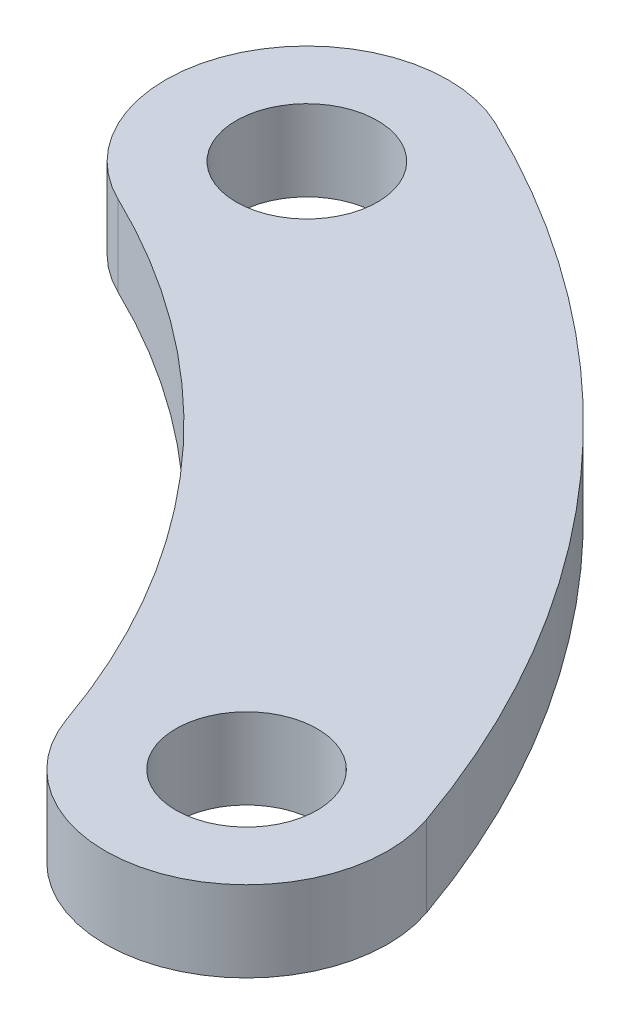
from build123d import *

# Parameters (mm, degrees)
SKETCH1_R           = 1.75
BOSS_EXTRUDE1_DEPTH = 2


with BuildPart() as part:
    # Sketch1 → Boss-Extrude1 (new body)
    with BuildSketch(Plane(origin=(0, 2, 0), x_dir=(1, 0, 0), z_dir=(0, 1, 0))):
        with BuildLine():
            ThreePointArc((26.108282991, 9.103848595), (20.637016257, 18.402066732), (12.023950872, 24.898737025))
            ThreePointArc((12.023950872, 24.898737025), (7.350192911, 23.269017259), (8.979912677, 18.595259297))
            ThreePointArc((8.979912677, 18.595259297), (15.412455179, 13.743315661), (19.498591095, 6.799076799))
            ThreePointArc((19.498591095, 6.799076799), (23.955822941, 4.646616748), (26.108282991, 9.103848595))
        make_face()
        with Locations((10.501931774, 21.746998161)):
            Circle(SKETCH1_R, mode=Mode.SUBTRACT)
        with Locations((22.803437043, 7.951462697)):
            Circle(SKETCH1_R, mode=Mode.SUBTRACT)
    extrude(amount=BOSS_EXTRUDE1_DEPTH)


solid = part.part
